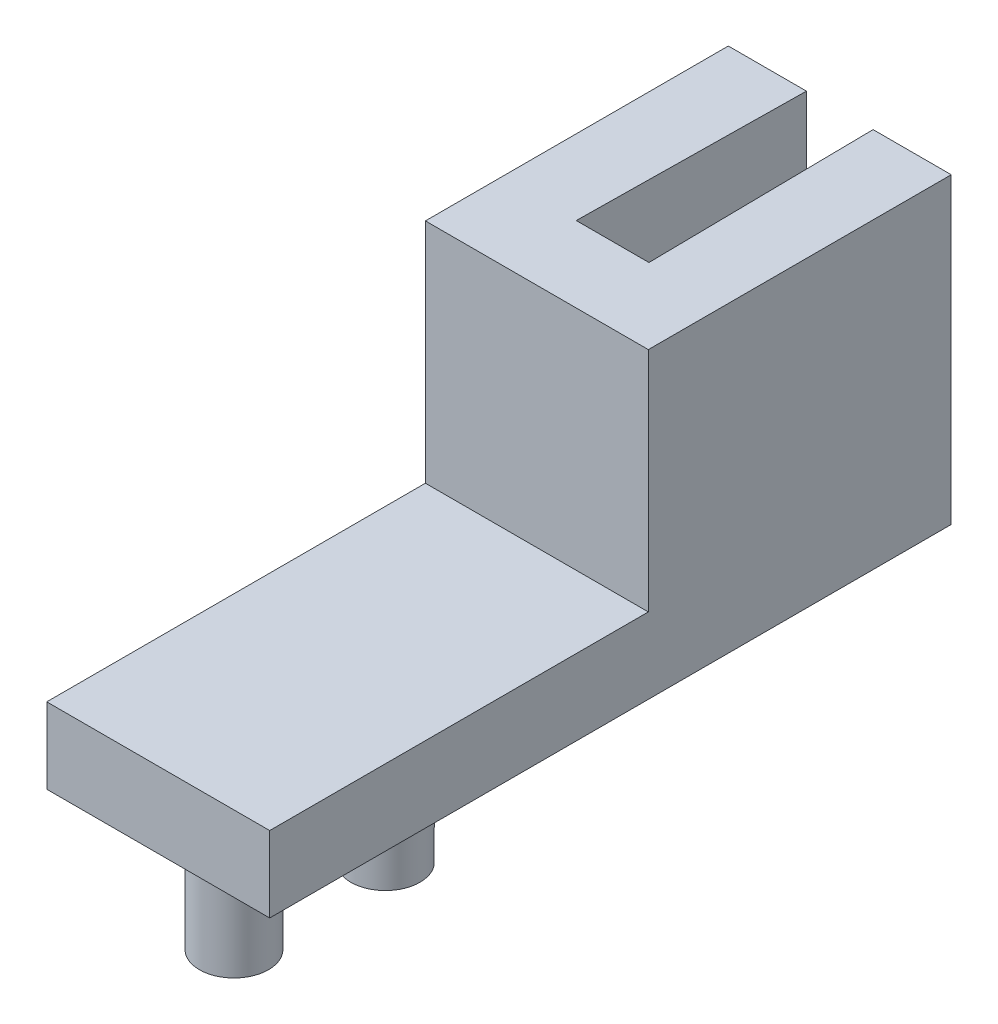
from build123d import *

# Parameters (mm, degrees)
SKETCH2_W           = 15.875
SKETCH2_H           = 3.175
BOSS_EXTRUDE1_DEPTH = 9.3472
CUT_EXTRUDE1_DEPTH  = 13.7
SKETCH4_R           = 1.45
BOSS_EXTRUDE2_DEPTH = 5.08


with BuildPart() as part:
    # Sketch2 → Boss-Extrude1 (new body)
    with BuildSketch(Plane(origin=(0, 0, 0), x_dir=(0, 0, -1), z_dir=(1, 0, 0))):
        with Locations((-7.9375, -1.5875)):
            Rectangle(SKETCH2_W, SKETCH2_H)
        Polygon((0, 9.525), (0, 0), (0, -3.175), (12.7, -3.175), (12.7, 9.525), align=None)
    extrude(amount=BOSS_EXTRUDE1_DEPTH)

    # Sketch3 → Cut-Extrude1 (cut, through all)
    with BuildSketch(Plane(origin=(0, 9.525, 0), x_dir=(1, 0, 0), z_dir=(0, 1, 0))):
        Polygon((3.2766, 12.7), (6.0706, 12.7), (6.1976, 3.175), (3.1496, 3.175), align=None)
    extrude(amount=-CUT_EXTRUDE1_DEPTH, mode=Mode.SUBTRACT)

    # Sketch4 → Boss-Extrude2 (add)
    with BuildSketch(Plane.XZ.offset(3.175)):
        with Locations((4.6736, 12.7)):
            Circle(SKETCH4_R)
        with Locations((4.6736, 6.35)):
            Circle(SKETCH4_R)
    extrude(amount=BOSS_EXTRUDE2_DEPTH)


solid = part.part
